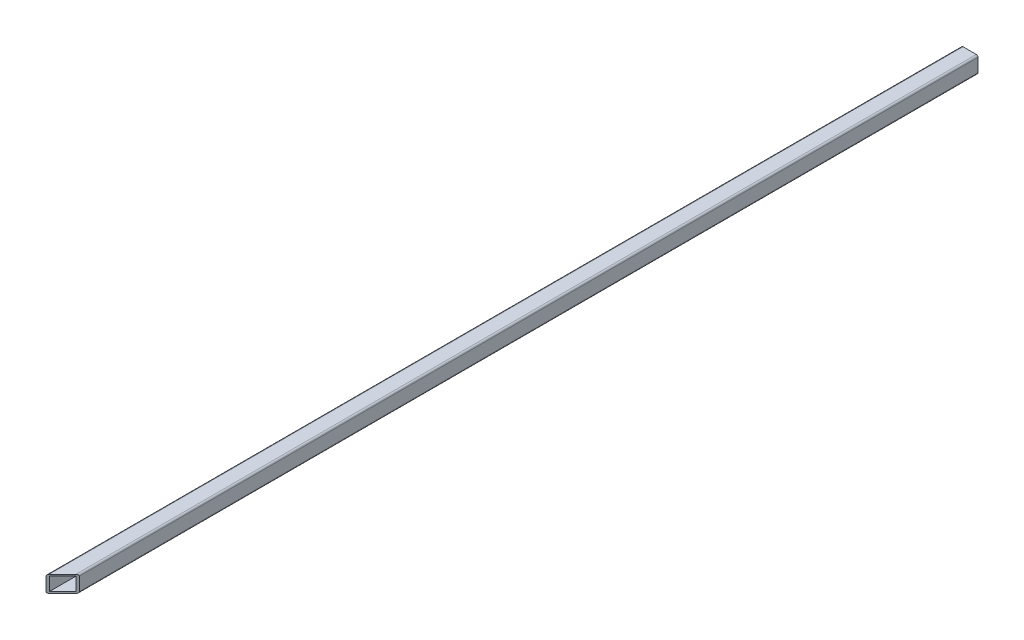
from build123d import *

# Parameters (mm, degrees)
SKETCH1_W           = 20
SKETCH1_H           = 20
BOSS_EXTRUDE1_DEPTH = 1100
FILLET1_R           = 2
SKETCH2_W           = 16
SKETCH2_H           = 16
CUT_EXTRUDE1_DEPTH  = 1101
CUT_EXTRUDE2_DEPTH  = 21


with BuildPart() as part:
    # Sketch1 → Boss-Extrude1 (new body)
    with BuildSketch(Plane.XY):
        with Locations((279.9, -40.85)):
            Rectangle(SKETCH1_W, SKETCH1_H)
    extrude(amount=BOSS_EXTRUDE1_DEPTH)

    # Fillet1
    fillet1_edges = [part.edges().sort_by_distance(p)[0] for p in [
        (269.9, -30.85, 550),
        (289.9, -30.85, 550),
        (289.9, -50.85, 550),
        (269.9, -50.85, 550),
    ]]
    fillet(fillet1_edges, radius=FILLET1_R)

    # Sketch2 → Cut-Extrude1 (cut, through all)
    with BuildSketch(Plane.XY.offset(1100)):
        with Locations((279.9, -40.85)):
            Rectangle(SKETCH2_W, SKETCH2_H)
    extrude(amount=-CUT_EXTRUDE1_DEPTH, mode=Mode.SUBTRACT)

    # Sketch3 → Cut-Extrude2 (cut, through all)
    with BuildSketch(Plane.XZ.offset(50.85)):
        Polygon((269.9, 1100), (289.9, 1080), (289.9, 1100), align=None)
    extrude(amount=-CUT_EXTRUDE2_DEPTH, mode=Mode.SUBTRACT)


solid = part.part
